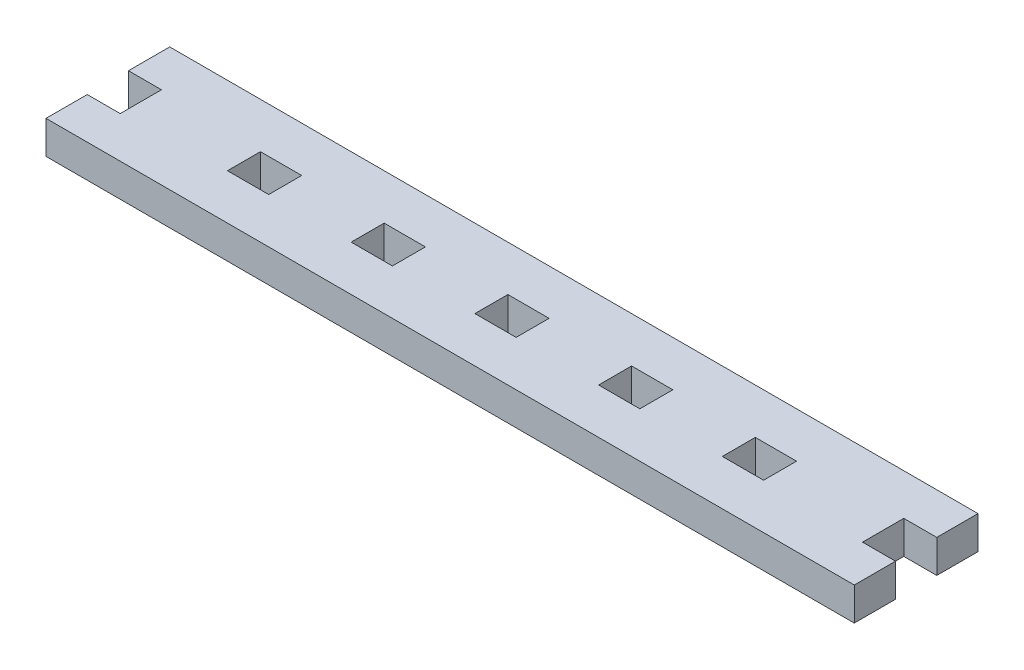
from build123d import *

# Parameters (mm, degrees)
BOSS_EXTRUDE1_DEPTH = 5.08
SKETCH2_W           = 6.35
SKETCH2_H           = 5.08
CUT_EXTRUDE1_DEPTH  = 6.08
LPATTERN1_COUNT     = 5
LPATTERN1_PITCH     = 19.05


with BuildPart() as part:
    # Sketch1 → Boss-Extrude1 (new body)
    with BuildSketch(Plane(origin=(0, 0, 0), x_dir=(1, 0, 0), z_dir=(0, 1, 0))):
        Polygon((0, 12.7), (0, 19.05), (124.46, 19.05), (124.46, 12.7), (119.38, 12.7), (119.38, 6.35), (124.46, 6.35), (124.46, 0), (0, 0), (0, 6.35), (5.08, 6.35), (5.08, 12.7), align=None)
    extrude(amount=BOSS_EXTRUDE1_DEPTH)

    # Sketch2 → Cut-Extrude1 (cut, through all)
    with BuildSketch(Plane(origin=(0, 5.08, 0), x_dir=(1, 0, 0), z_dir=(0, 1, 0))):
        with Locations((24.13, 9.525)):
            Rectangle(SKETCH2_W, SKETCH2_H)
    cut_extrude1 = extrude(amount=-CUT_EXTRUDE1_DEPTH, mode=Mode.SUBTRACT)

    # LPattern1: Cut-Extrude1 ×5
    with Locations(*[(i * LPATTERN1_PITCH, 0, 0) for i in range(1, LPATTERN1_COUNT)]):
        add(cut_extrude1, mode=Mode.SUBTRACT)


solid = part.part
